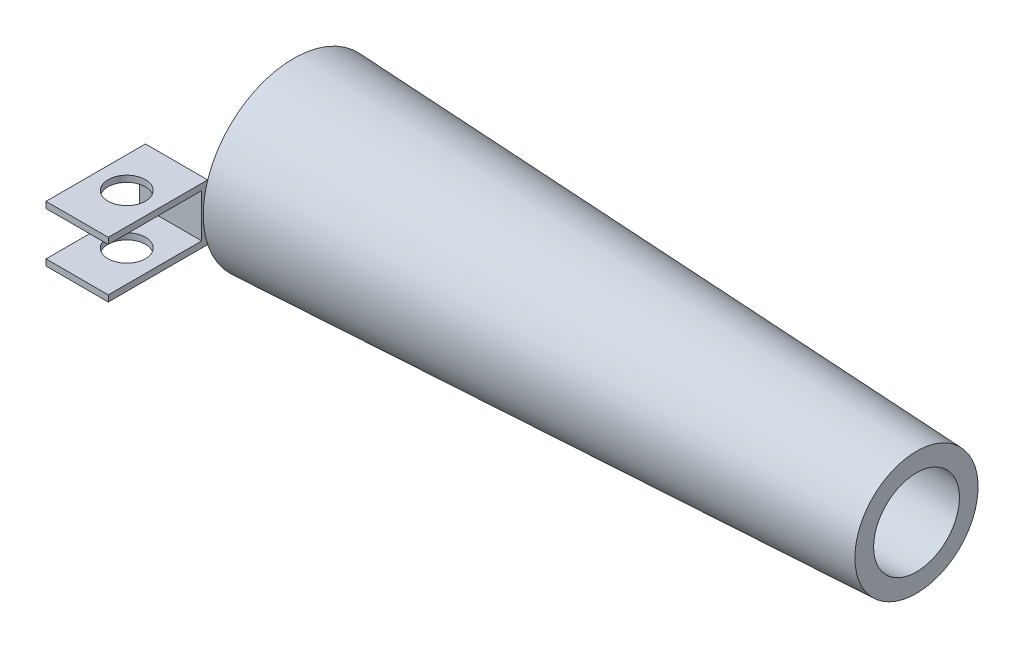
from build123d import *

# Parameters (mm, degrees)
BOSS_EXTRUDE1_DEPTH = 1
SKETCH5_R           = 0.3
CUT_EXTRUDE2_DEPTH  = 1
SKETCH6_W           = 1
SKETCH6_H           = 0.7
CUT_EXTRUDE3_DEPTH  = 1.5


with BuildPart() as part:
    # Sketch2 → Revolve2 (revolve)
    with BuildSketch(Plane.XY):
        Polygon((0, 1), (0, 0.3), (0.3, 0.3), (0.3, 0.68585997), (10, 0.238955255), (10, 0.539273489), align=None)
    revolve(axis=Axis((0, -0.45, 0), (1, 0, 0)))


with BuildPart() as body_2:
    # Sketch3 → Boss-Extrude1 (new body)
    with BuildSketch(Plane.ZY):
        with BuildLine():
            Line((2.974562536, 0), (1.378404875, 0))
            ThreePointArc((1.378404875, 0), (1.431989363, -0.222170095), (1.45, -0.45))
            ThreePointArc((1.45, -0.45), (1.431989363, -0.677829905), (1.378404875, -0.9))
            Line((1.378404875, -0.9), (2.974562536, -0.9))
            Line((2.974562536, -0.9), (2.974562536, 0))
        make_face()
    extrude(amount=BOSS_EXTRUDE1_DEPTH)

    # Sketch5 → Cut-Extrude2 (cut)
    with BuildSketch(Plane(origin=(0, 0, 0), x_dir=(1, 0, 0), z_dir=(0, 1, 0))):
        with Locations((-0.50361821, -2.174562536)):
            Circle(SKETCH5_R)
    extrude(amount=-CUT_EXTRUDE2_DEPTH, mode=Mode.SUBTRACT)

    # Sketch6 → Cut-Extrude3 (cut)
    with BuildSketch(Plane.XY.offset(2.974562536)):
        with Locations((-0.5, -0.45)):
            Rectangle(SKETCH6_W, SKETCH6_H)
    extrude(amount=-CUT_EXTRUDE3_DEPTH, mode=Mode.SUBTRACT)


solid = Compound([part.part, body_2.part])
